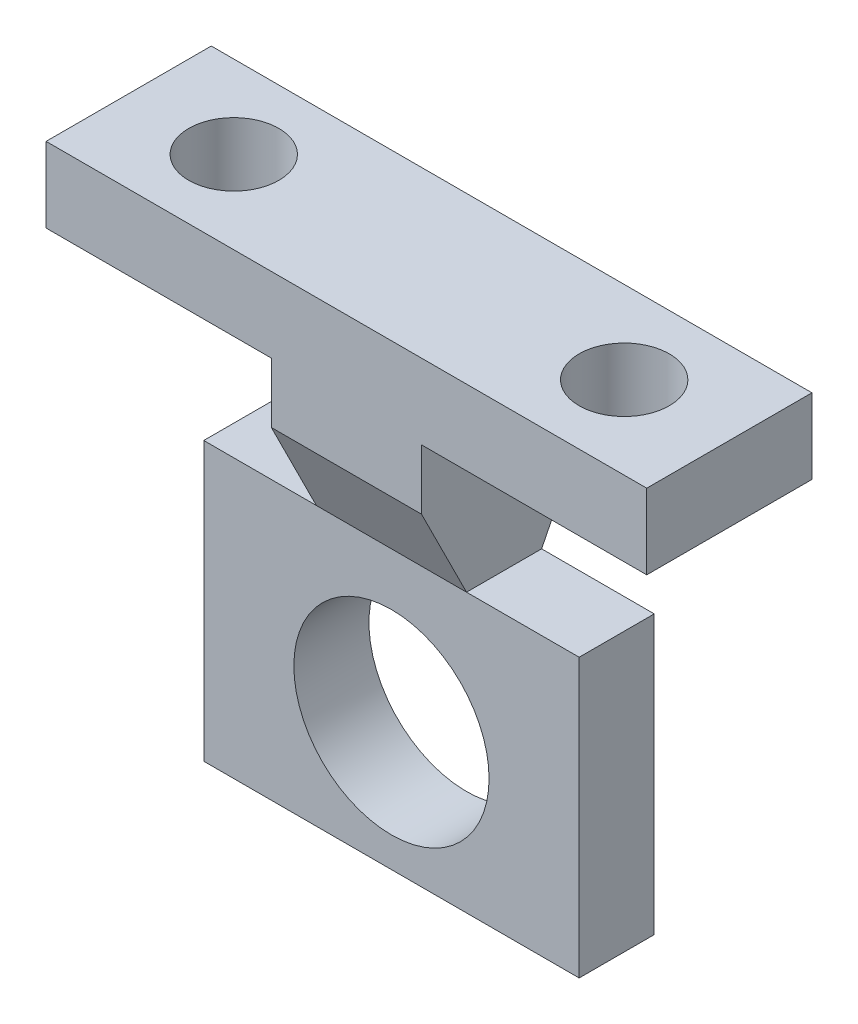
from build123d import *

# Parameters (mm, degrees)
SKETCH1_W                = 40
SKETCH1_H                = 50
BOSS_EXTRUDE1_DEPTH      = 15
BOSS_EXTRUDE1_DEPTH_BACK = 0.0001
SKETCH2_R                = 6.5
CUT_EXTRUDE1_DEPTH       = 30
SKETCH3_W                = 15
SKETCH3_H                = 10
CUT_EXTRUDE4_DEPTH       = 30
SKETCH5_R                = 3
CUT_EXTRUDE5_DEPTH       = 10
SKETCH6_W                = 40
SKETCH6_H                = 35
CUT_EXTRUDE7_DEPTH       = 3.5
SKETCH7_W                = 40
SKETCH7_H                = 35
CUT_EXTRUDE8_DEPTH       = 3.5
CUT_EXTRUDE9_DEPTH       = 15
SKETCH10_R               = 6.5
CUT_EXTRUDE11_DEPTH      = 10
SKETCH11_W               = 40
SKETCH11_H               = 16.5
CUT_EXTRUDE16_DEPTH      = 10
SKETCH12_W               = 40
SKETCH12_H               = 18.5
CUT_EXTRUDE17_DEPTH      = 1.5
SKETCH13_W               = 40
SKETCH13_H               = 18.5
CUT_EXTRUDE18_DEPTH      = 1.5
CUT_EXTRUDE19_DEPTH      = 150
SKETCH15_W               = 40
SKETCH15_H               = 2
CUT_EXTRUDE21_DEPTH      = 10
SKETCH16_W               = 40
SKETCH16_H               = 5
CUT_EXTRUDE22_DEPTH      = 1
SKETCH17_W               = 7.5
SKETCH17_H               = 18.5
CUT_EXTRUDE23_DEPTH      = 10


with BuildPart() as part:
    # Sketch1 → Boss-Extrude1 (new body, two sides)
    with BuildSketch(Plane.XY) as boss_extrude1_sk:
        with Locations((20, 25)):
            Rectangle(SKETCH1_W, SKETCH1_H)
    extrude(amount=BOSS_EXTRUDE1_DEPTH)
    extrude(boss_extrude1_sk.sketch, amount=-BOSS_EXTRUDE1_DEPTH_BACK)

    # Sketch2 → Cut-Extrude1 (cut)
    with BuildSketch(Plane.XY.offset(15)):
        with Locations((20, 10)):
            Circle(SKETCH2_R)
    extrude(amount=-CUT_EXTRUDE1_DEPTH, mode=Mode.SUBTRACT)

    # Sketch3 → Cut-Extrude4 (cut)
    with BuildSketch(Plane(origin=(0, 0, -0.0001), x_dir=(-1, 0, 0), z_dir=(0, 0, -1))):
        with Locations((-32.5, 40)):
            Rectangle(SKETCH3_W, SKETCH3_H)
        with Locations((-7.5, 40)):
            Rectangle(SKETCH3_W, SKETCH3_H)
    extrude(amount=-CUT_EXTRUDE4_DEPTH, mode=Mode.SUBTRACT)

    # Sketch5 → Cut-Extrude5 (cut)
    with BuildSketch(Plane(origin=(0, 50, 0), x_dir=(1, 0, 0), z_dir=(0, 1, 0))):
        with Locations((7, -7.5)):
            Circle(SKETCH5_R)
        with Locations((33, -7.5)):
            Circle(SKETCH5_R)
    extrude(amount=-CUT_EXTRUDE5_DEPTH, mode=Mode.SUBTRACT)

    # Sketch6 → Cut-Extrude7 (cut)
    with BuildSketch(Plane.XY.offset(15)):
        with Locations((20, 17.5)):
            Rectangle(SKETCH6_W, SKETCH6_H)
    extrude(amount=-CUT_EXTRUDE7_DEPTH, mode=Mode.SUBTRACT)

    # Sketch7 → Cut-Extrude8 (cut)
    with BuildSketch(Plane(origin=(0, 0, -0.0001), x_dir=(-1, 0, 0), z_dir=(0, 0, -1))):
        with Locations((-20, 17.5)):
            Rectangle(SKETCH7_W, SKETCH7_H)
    extrude(amount=-CUT_EXTRUDE8_DEPTH, mode=Mode.SUBTRACT)

    # Sketch8 → Cut-Extrude9 (cut)
    with BuildSketch(Plane.ZY.offset(-15)):
        Polygon((-0.0001, 35), (3.4999, 35), (-0.0001, 45), align=None)
        Polygon((11.5, 35), (15, 35), (15, 45), align=None)
    extrude(amount=-CUT_EXTRUDE9_DEPTH, mode=Mode.SUBTRACT)

    # Sketch10 → Cut-Extrude11 (cut)
    with BuildSketch(Plane.XY.offset(11.5)):
        with Locations((20, 25.001654813)):
            Circle(SKETCH10_R)
    extrude(amount=-CUT_EXTRUDE11_DEPTH, mode=Mode.SUBTRACT)

    # Sketch11 → Cut-Extrude16 (cut)
    with BuildSketch(Plane.XY.offset(11.5)):
        with Locations((20, 8.25)):
            Rectangle(SKETCH11_W, SKETCH11_H)
    extrude(amount=-CUT_EXTRUDE16_DEPTH, mode=Mode.SUBTRACT)

    # Sketch12 → Cut-Extrude17 (cut)
    with BuildSketch(Plane.XY.offset(11.5)):
        with Locations((20, 25.75)):
            Rectangle(SKETCH12_W, SKETCH12_H)
    extrude(amount=-CUT_EXTRUDE17_DEPTH, mode=Mode.SUBTRACT)

    # Sketch13 → Cut-Extrude18 (cut)
    with BuildSketch(Plane(origin=(0, 0, 3.4999), x_dir=(-1, 0, 0), z_dir=(0, 0, -1))):
        with Locations((-20, 25.75)):
            Rectangle(SKETCH13_W, SKETCH13_H)
    extrude(amount=-CUT_EXTRUDE18_DEPTH, mode=Mode.SUBTRACT)

    # Sketch14 → Cut-Extrude19 (cut)
    with BuildSketch(Plane.ZY.offset(-15)):
        Polygon((4.9999, 35), (-0.0001, 45), (3.4999, 35), align=None)
        Polygon((10, 35), (11.5, 35), (15, 45), align=None)
    extrude(amount=-CUT_EXTRUDE19_DEPTH, mode=Mode.SUBTRACT)

    # Sketch15 → Cut-Extrude21 (cut)
    with BuildSketch(Plane(origin=(0, 50, 0), x_dir=(1, 0, 0), z_dir=(0, 1, 0))):
        Polygon((0, 0), (0, -2), (40, -2), (40, 0.0001), align=None)
        with Locations((20, -14)):
            Rectangle(SKETCH15_W, SKETCH15_H)
    extrude(amount=-CUT_EXTRUDE21_DEPTH, mode=Mode.SUBTRACT)

    # Sketch16 → Cut-Extrude22 (cut)
    with BuildSketch(Plane(origin=(0, 0, -0.0001), x_dir=(-1, 0, 0), z_dir=(0, 0, -1))):
        with Locations((-20, 47.5)):
            Rectangle(SKETCH16_W, SKETCH16_H)
    extrude(amount=-CUT_EXTRUDE22_DEPTH, mode=Mode.SUBTRACT)

    # Sketch17 → Cut-Extrude23 (cut)
    with BuildSketch(Plane(origin=(0, 0, 4.9999), x_dir=(-1, 0, 0), z_dir=(0, 0, -1))):
        with Locations((-36.25, 25.75)):
            Rectangle(SKETCH17_W, SKETCH17_H)
        with Locations((-3.75, 25.75)):
            Rectangle(SKETCH17_W, SKETCH17_H)
    extrude(amount=-CUT_EXTRUDE23_DEPTH, mode=Mode.SUBTRACT)


solid = part.part
